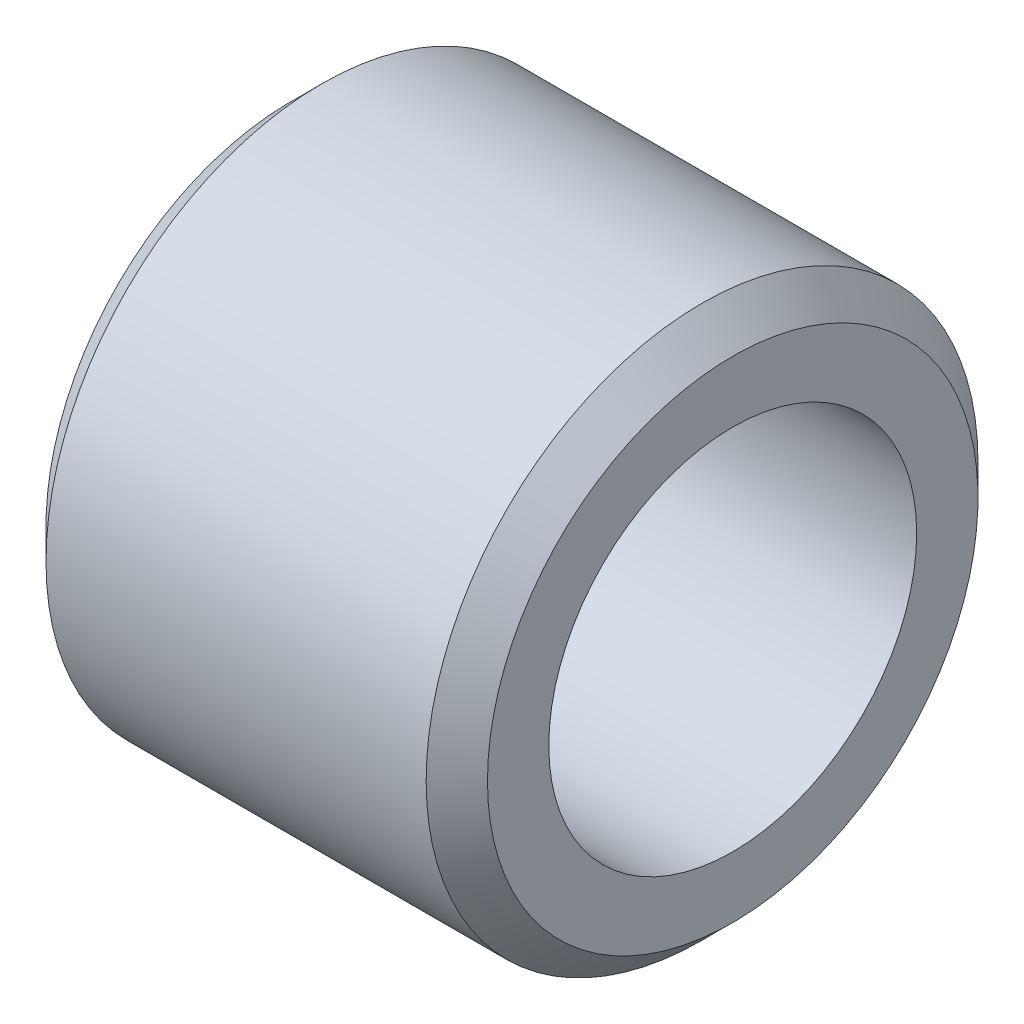
from build123d import *

# Parameters (mm, degrees)
SKETCH1_W     = 7.2
SKETCH1_H     = 1.5
CHAMFER1_SIZE = 0.5


with BuildPart() as part:
    # Sketch1 → Revolve1 (revolve)
    with BuildSketch(Plane.XY):
        with Locations((3.6, 3.75)):
            Rectangle(SKETCH1_W, SKETCH1_H)
    revolve(axis=Axis((0, 0, 0), (1, 0, 0)))

    # Chamfer1
    chamfer1_edges = [part.edges().sort_by_distance(p)[0] for p in [
        (7.2, -4.5, 0),
        (0, -4.5, 0),
    ]]
    chamfer(chamfer1_edges, length=CHAMFER1_SIZE)


solid = part.part
